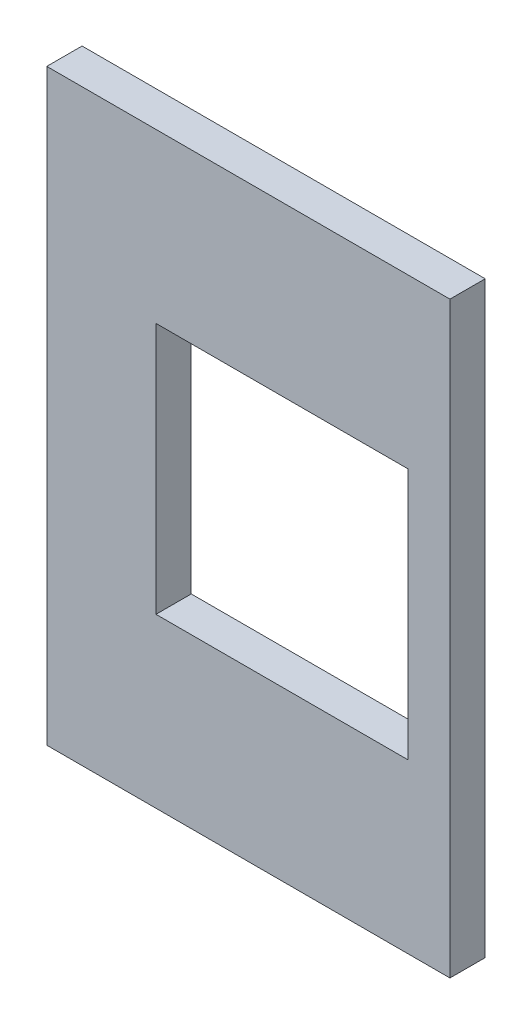
from build123d import *

# Parameters (mm, degrees)
SKETCH1_W           = 25.4
SKETCH1_H           = 44.45
SKETCH1_W_2         = 19.05
SKETCH1_H_2         = 19.05
BOSS_EXTRUDE1_DEPTH = 3.175
SKETCH4_W           = 3.175
SKETCH4_H           = 44.45
BOSS_EXTRUDE3_DEPTH = 5.08
MOVE_FACE1_BY       = 0.508


with BuildPart() as part:
    # Sketch1 → Boss-Extrude1 (new body)
    with BuildSketch(Plane.XY):
        Rectangle(SKETCH1_W, SKETCH1_H)
        Rectangle(SKETCH1_W_2, SKETCH1_H_2, mode=Mode.SUBTRACT)
    extrude(amount=BOSS_EXTRUDE1_DEPTH)

    # Sketch4 → Boss-Extrude3 (add)
    with BuildSketch(Plane.ZY.offset(12.7)):
        with Locations((1.5875, 0)):
            Rectangle(SKETCH4_W, SKETCH4_H)
    extrude(amount=BOSS_EXTRUDE3_DEPTH)

    # Move Face1: a face moved inward by 0.508
    extrude(part.faces().sort_by_distance((-2.54, -11.1125, 3.175))[0], amount=MOVE_FACE1_BY, dir=(0, 0, -1), mode=Mode.SUBTRACT)


solid = part.part
